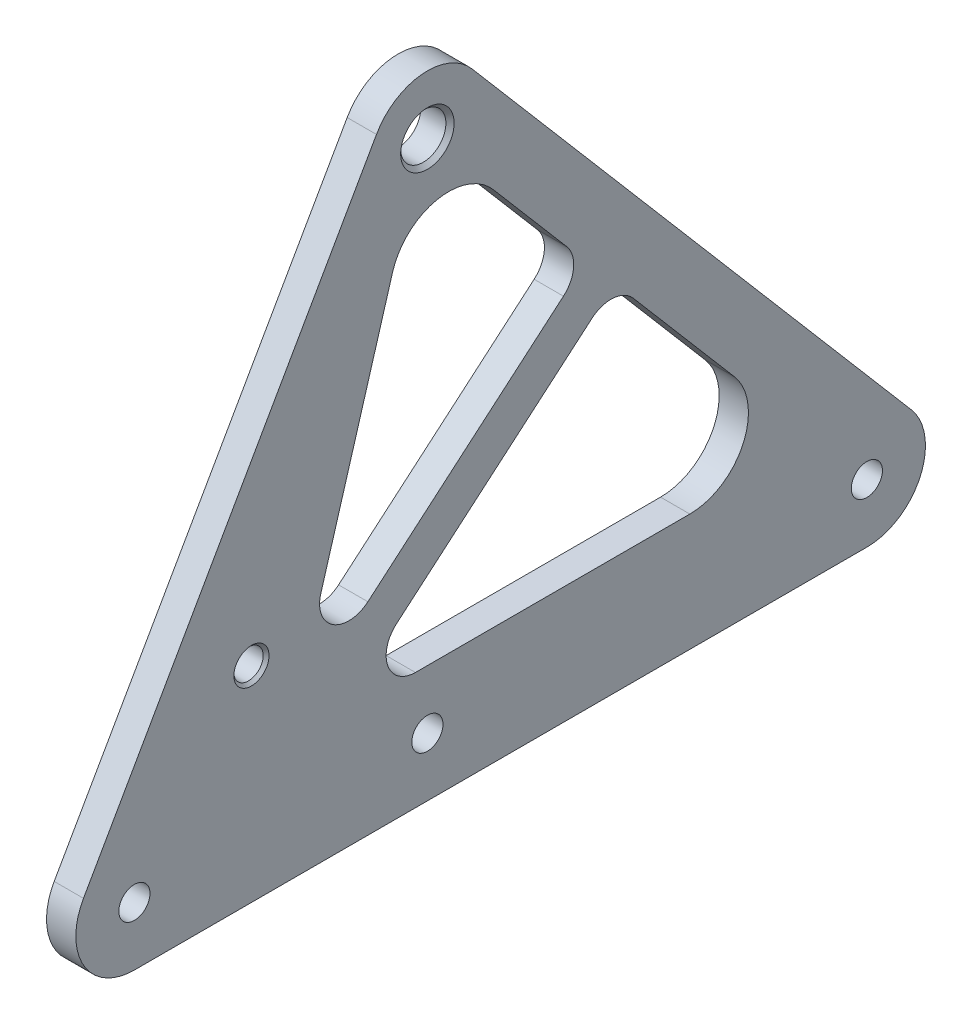
from build123d import *

# Parameters (mm, degrees)
BOSS_EXTRUDE1_DEPTH                  = 6.35
CUT_EXTRUDE1_REACH                   = 8.35
SKETCH2_R                            = 3.3782
F_3_8_CLEARANCE_HOLE1_D              = 9.8044
F_3_8_CLEARANCE_HOLE1_CSINK_D        = 11.58748
F_3_8_CLEARANCE_HOLE1_CSINK_ANGLE    = 90
F_1_4_0_2500_DOWEL_HOLE1_D           = 6.35
F_1_4_0_2500_DOWEL_HOLE1_CSINK_D     = 7.62
F_1_4_0_2500_DOWEL_HOLE1_CSINK_ANGLE = 90
CUT_EXTRUDE2_DEPTH                   = 7.35


with BuildPart() as part:
    # Sketch1 → Boss-Extrude1 (new body)
    with BuildSketch(Plane(origin=(0, 0, 0), x_dir=(0, 0, -1), z_dir=(1, 0, 0))):
        with BuildLine():
            Line((-74.539032088, -105.353687095), (-11.039032088, 6.279312905))
            ThreePointArc((-11.039032088, 6.279312905), (-1.199563995, 12.643221355), (9.661154553, 8.243305933))
            Line((9.661154553, 8.243305933), (104.911154553, -103.389694067))
            ThreePointArc((104.911154553, -103.389694067), (106.782128714, -116.95277512), (95.25, -124.333))
            Line((95.25, -124.333), (-63.5, -124.333))
            ThreePointArc((-63.5, -124.333), (-74.478098057, -118.018245731), (-74.539032088, -105.353687095))
        make_face()
    extrude(amount=BOSS_EXTRUDE1_DEPTH)

    # Sketch2 → Cut-Extrude1 (cut, up to next)
    with BuildSketch(Plane(origin=(6.35, 0, 0), x_dir=(0, 0, -1), z_dir=(1, 0, 0)), mode=Mode.PRIVATE) as cut_extrude1_sk1:
        with Locations((-63.5, -111.633)):
            Circle(SKETCH2_R)
    cut_extrude1_tool1 = extrude(cut_extrude1_sk1.sketch, amount=-CUT_EXTRUDE1_REACH, mode=Mode.PRIVATE) & part.part
    add(cut_extrude1_tool1.solids().sort_by_distance((6.35, -111.633, 63.5))[0], mode=Mode.SUBTRACT)
    # Sketch2 → Cut-Extrude1 (cut, up to next)
    with BuildSketch(Plane(origin=(6.35, 0, 0), x_dir=(0, 0, -1), z_dir=(1, 0, 0)), mode=Mode.PRIVATE) as cut_extrude1_sk2:
        with Locations((0, -111.633)):
            Circle(SKETCH2_R)
    cut_extrude1_tool2 = extrude(cut_extrude1_sk2.sketch, amount=-CUT_EXTRUDE1_REACH, mode=Mode.PRIVATE) & part.part
    add(cut_extrude1_tool2.solids().sort_by_distance((6.35, -111.633, 0))[0], mode=Mode.SUBTRACT)
    # Sketch2 → Cut-Extrude1 (cut, up to next)
    with BuildSketch(Plane(origin=(6.35, 0, 0), x_dir=(0, 0, -1), z_dir=(1, 0, 0)), mode=Mode.PRIVATE) as cut_extrude1_sk3:
        with Locations((95.25, -111.633)):
            Circle(SKETCH2_R)
    cut_extrude1_tool3 = extrude(cut_extrude1_sk3.sketch, amount=-CUT_EXTRUDE1_REACH, mode=Mode.PRIVATE) & part.part
    add(cut_extrude1_tool3.solids().sort_by_distance((6.35, -111.633, -95.25))[0], mode=Mode.SUBTRACT)

    # 3/8 Clearance Hole1 (through all)
    with Locations(Plane(origin=(6.35, 0, 0), x_dir=(0, 0, -1), z_dir=(1, 0, 0))):
        with Locations((0, 0)):
            CounterSinkHole(F_3_8_CLEARANCE_HOLE1_D / 2, F_3_8_CLEARANCE_HOLE1_CSINK_D / 2, counter_sink_angle=F_3_8_CLEARANCE_HOLE1_CSINK_ANGLE)

    # 1/4 (0.2500) Dowel Hole1 (through all)
    with Locations(Plane(origin=(6.35, 0, 0), x_dir=(0, 0, -1), z_dir=(1, 0, 0))):
        with Locations((-38.134262993, -79.883)):
            CounterSinkHole(F_1_4_0_2500_DOWEL_HOLE1_D / 2, F_1_4_0_2500_DOWEL_HOLE1_CSINK_D / 2, counter_sink_angle=F_1_4_0_2500_DOWEL_HOLE1_CSINK_ANGLE)

    # Sketch7 → Cut-Extrude2 (cut, through all)
    with BuildSketch(Plane(origin=(6.35, 0, 0), x_dir=(0, 0, -1), z_dir=(1, 0, 0))):
        with BuildLine():
            Line((-7.560548241, -21.370623035), (-23.109121722, -73.87283281))
            ThreePointArc((-23.109121722, -73.87283281), (-20.480108275, -81.000798522), (-12.898859563, -80.506556809))
            Line((-12.898859563, -80.506556809), (29.486651444, -44.341445027))
            ThreePointArc((29.486651444, -44.341445027), (31.69518119, -40.012152938), (30.195575755, -35.389214784))
            Line((30.195575755, -35.389214784), (14.277824698, -16.733610546))
            ThreePointArc((14.277824698, -16.733610546), (1.978846134, -12.553878022), (-7.560548241, -21.370623035))
        make_face()
        with BuildLine():
            Line((-2.594727147, -98.933), (56.882953013, -98.933))
            ThreePointArc((56.882953013, -98.933), (68.415081727, -91.55277512), (66.544107566, -77.989694067))
            Line((66.544107566, -77.989694067), (44.621361137, -52.296235252))
            ThreePointArc((44.621361137, -52.296235252), (40.292069047, -50.087705507), (35.669130894, -51.587310942))
            Line((35.669130894, -51.587310942), (-6.716380114, -87.752422723))
            ThreePointArc((-6.716380114, -87.752422723), (-8.552774886, -94.779398677), (-2.594727147, -98.933))
        make_face()
    extrude(amount=-CUT_EXTRUDE2_DEPTH, mode=Mode.SUBTRACT)


solid = part.part
